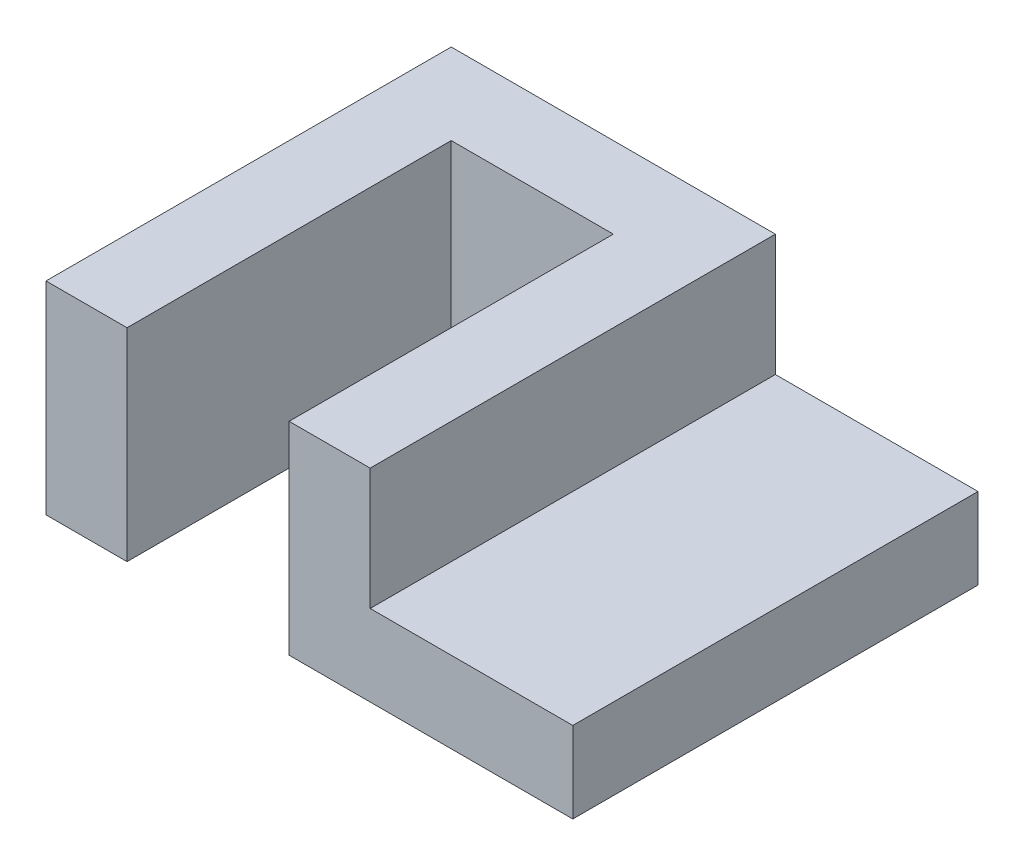
from build123d import *

# Parameters (mm, degrees)
BOSS_EXTRUDE1_DEPTH = 50
SKETCH3_W           = 100
SKETCH3_H           = 20
BOSS_EXTRUDE2_DEPTH = 50


with BuildPart() as part:
    # Sketch2 → Boss-Extrude1 (new body)
    with BuildSketch(Plane(origin=(0, 0, 0), x_dir=(1, 0, 0), z_dir=(0, 1, 0))):
        Polygon((0, 0), (0, 100), (80, 100), (80, 0), (60, 0), (60, 80), (20, 80), (20, 0), align=None)
    extrude(amount=BOSS_EXTRUDE1_DEPTH)

    # Sketch3 → Boss-Extrude2 (add)
    with BuildSketch(Plane(origin=(80, 0, 0), x_dir=(0, 0, -1), z_dir=(1, 0, 0))):
        with Locations((50, 10)):
            Rectangle(SKETCH3_W, SKETCH3_H)
    extrude(amount=BOSS_EXTRUDE2_DEPTH)


solid = part.part
